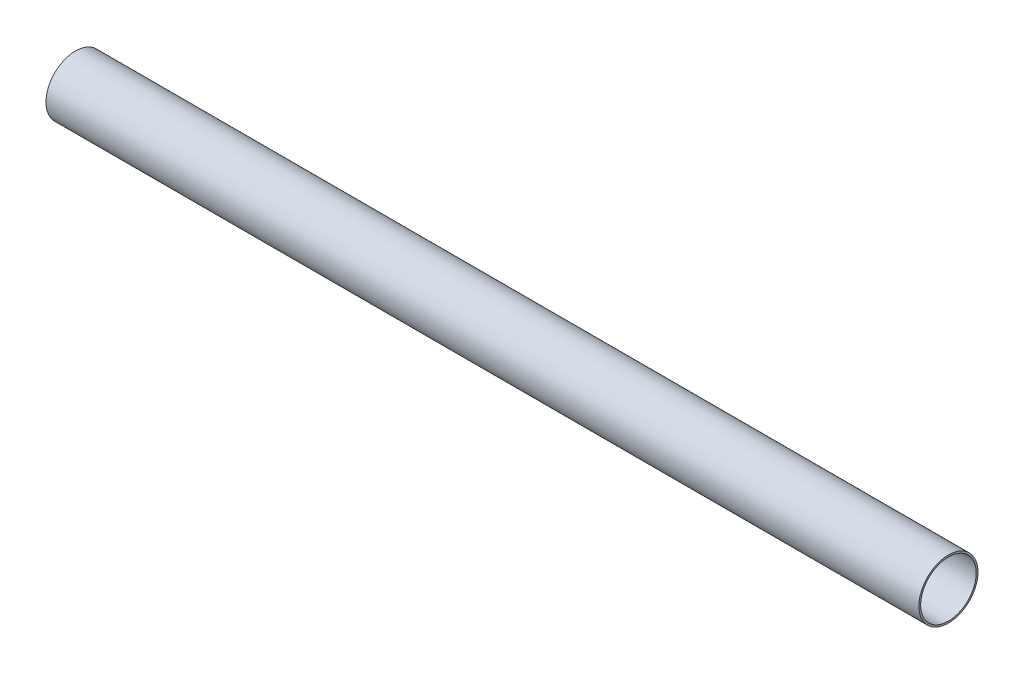
from build123d import *

# Parameters (mm, degrees)
SKETCH1_R      = 20.6375
SKETCH1_R_2    = 19.3929
EXTRUDE1_DEPTH = 304.8


with BuildPart() as part:
    # Sketch1 → Extrude1 (new body, symmetric)
    with BuildSketch(Plane(origin=(0, 0, 0), x_dir=(0, 0, -1), z_dir=(1, 0, 0))):
        Circle(SKETCH1_R)
        Circle(SKETCH1_R_2, mode=Mode.SUBTRACT)
    extrude(amount=EXTRUDE1_DEPTH, both=True)


solid = part.part
